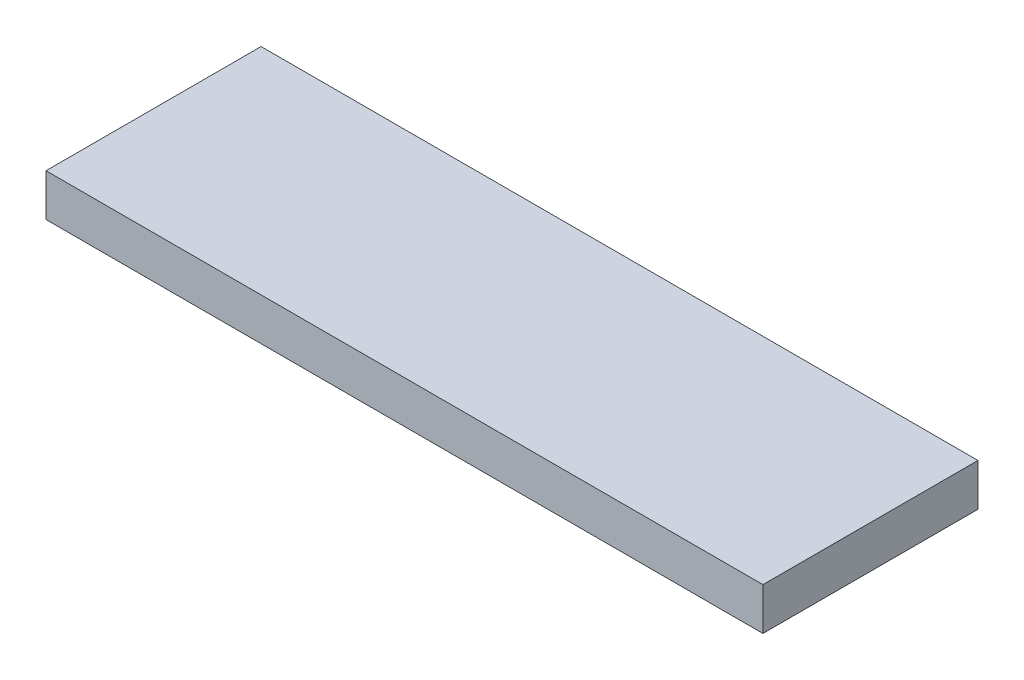
from build123d import *

# Parameters (mm, degrees)
SKETCH1_W           = 50
SKETCH1_H           = 15
BOSS_EXTRUDE1_DEPTH = 2.95


with BuildPart() as part:
    # Sketch1 → Boss-Extrude1 (new body)
    with BuildSketch(Plane(origin=(0, 0, 0), x_dir=(1, 0, 0), z_dir=(0, 1, 0))):
        with Locations((0.053882353, 25.547176471)):
            Rectangle(SKETCH1_W, SKETCH1_H)
    extrude(amount=BOSS_EXTRUDE1_DEPTH)


solid = part.part
